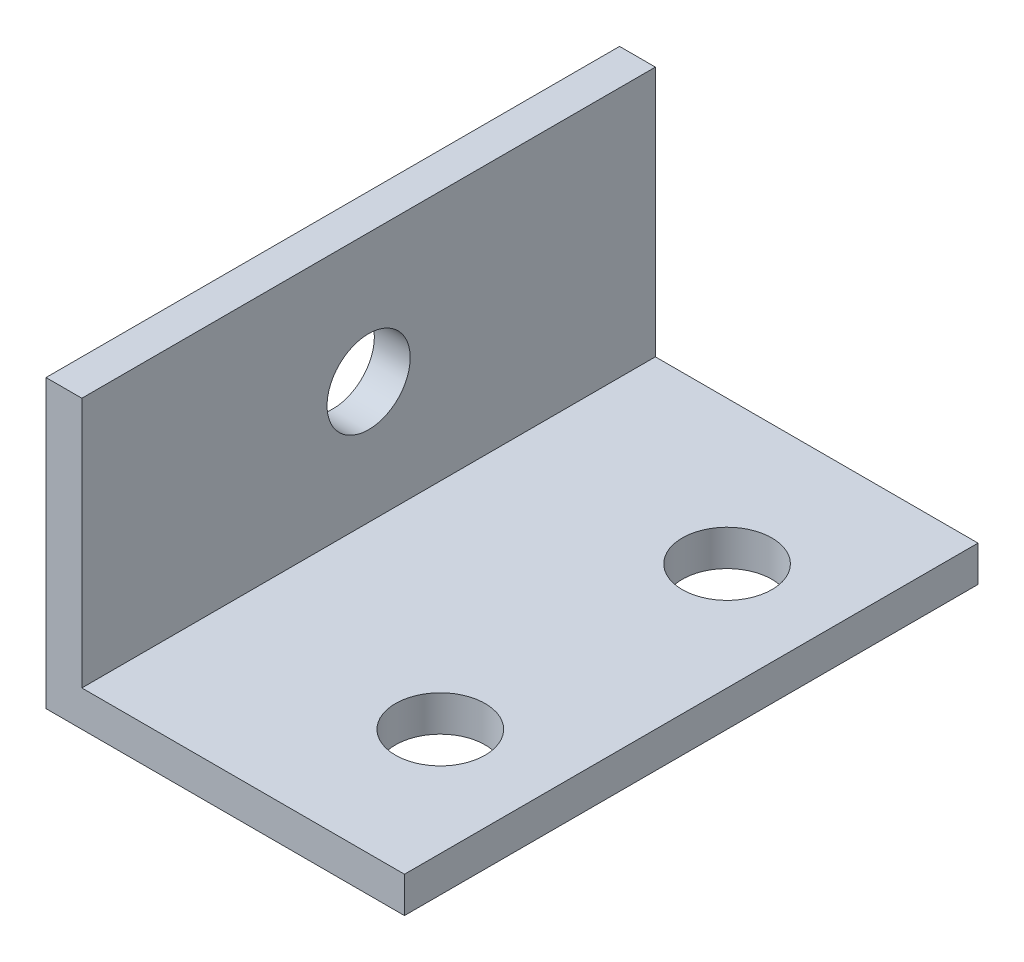
from build123d import *

# Parameters (mm, degrees)
SKETCH1_W           = 3.175
SKETCH1_H           = 25.4
SKETCH1_W_2         = 28.575
SKETCH1_H_2         = 3.175
BOSS_EXTRUDE1_DEPTH = 50.8
POT_MOUNT_REACH     = 5.175
SKETCH2_R           = 3.683
BASE_MOUNT_REACH    = 5.175
SKETCH3_R           = 3.96875


with BuildPart() as part:
    # Sketch1 → Boss-Extrude1 (new body)
    with BuildSketch(Plane.XY):
        with Locations((1.5875, 12.7)):
            Rectangle(SKETCH1_W, SKETCH1_H)
        with Locations((17.4625, 1.5875)):
            Rectangle(SKETCH1_W_2, SKETCH1_H_2)
    extrude(amount=BOSS_EXTRUDE1_DEPTH)

    # Sketch2 → Pot Mount (cut, up to next)
    with BuildSketch(Plane(origin=(3.175, 0, 0), x_dir=(0, 0, -1), z_dir=(1, 0, 0)), mode=Mode.PRIVATE) as pot_mount_sk1:
        with Locations((-25.4, 13.97)):
            Circle(SKETCH2_R)
    pot_mount_tool1 = extrude(pot_mount_sk1.sketch, amount=-POT_MOUNT_REACH, mode=Mode.PRIVATE) & part.part
    add(pot_mount_tool1.solids().sort_by_distance((3.175, 13.97, 25.4))[0], mode=Mode.SUBTRACT)

    # Sketch3 → Base Mount (cut, up to next)
    with BuildSketch(Plane(origin=(0, 3.175, 0), x_dir=(1, 0, 0), z_dir=(0, 1, 0)), mode=Mode.PRIVATE) as base_mount_sk1:
        with Locations((22.225, -38.1)):
            Circle(SKETCH3_R)
    base_mount_tool1 = extrude(base_mount_sk1.sketch, amount=-BASE_MOUNT_REACH, mode=Mode.PRIVATE) & part.part
    add(base_mount_tool1.solids().sort_by_distance((22.225, 3.175, 38.1))[0], mode=Mode.SUBTRACT)
    # Sketch3 → Base Mount (cut, up to next)
    with BuildSketch(Plane(origin=(0, 3.175, 0), x_dir=(1, 0, 0), z_dir=(0, 1, 0)), mode=Mode.PRIVATE) as base_mount_sk2:
        with Locations((22.225, -12.7)):
            Circle(SKETCH3_R)
    base_mount_tool2 = extrude(base_mount_sk2.sketch, amount=-BASE_MOUNT_REACH, mode=Mode.PRIVATE) & part.part
    add(base_mount_tool2.solids().sort_by_distance((22.225, 3.175, 12.7))[0], mode=Mode.SUBTRACT)


solid = part.part
